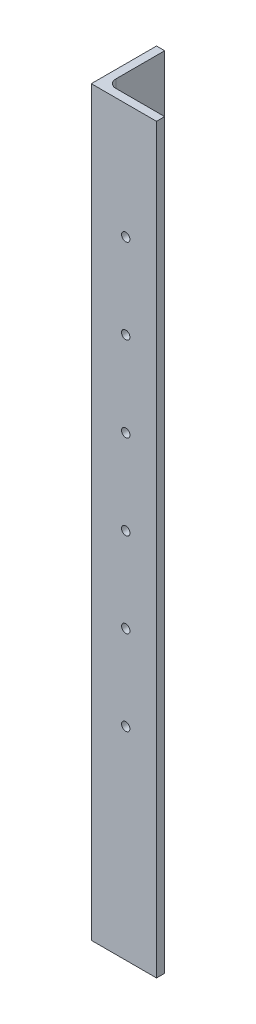
from build123d import *

# Parameters (mm, degrees)
BOSS_EXTRUDE1_DEPTH      = 577.85
FILLET1_R                = 6.35
F_0_257_DIAMETER_HOLE1_D = 6.5278
LPATTERN1_COUNT          = 6
LPATTERN1_PITCH          = 66.04
F_0_257_DIAMETER_HOLE2_D = 6.5278
LPATTERN2_COUNT          = 6
LPATTERN2_PITCH          = 66.04


with BuildPart() as part:
    # Sketch2 → Boss-Extrude1 (new body)
    with BuildSketch(Plane(origin=(0, 6.35, 0), x_dir=(1, 0, 0), z_dir=(0, 1, 0))):
        Polygon((-304.8, -406.4), (-304.8, -457.2), (-254, -457.2), (-254, -450.85), (-298.45, -450.85), (-298.45, -406.4), align=None)
    extrude(amount=BOSS_EXTRUDE1_DEPTH)

    # Fillet1
    fillet1_edges = [part.edges().sort_by_distance(p)[0] for p in [
        (-298.45, 295.275, 450.85),
    ]]
    fillet(fillet1_edges, radius=FILLET1_R)

    # F (0.257) Diameter Hole1 (through all)
    with Locations(Plane.XY.offset(457.2)):
        with Locations((-535.515028223, 347.01452534), (-277.982504407, 164.015269696)):
            f_0_257_diameter_hole1 = Hole(F_0_257_DIAMETER_HOLE1_D / 2)

    # LPattern1: F (0.257) Diameter Hole1 ×6
    with Locations(*[(0, i * LPATTERN1_PITCH, 0) for i in range(1, LPATTERN1_COUNT)]):
        add(f_0_257_diameter_hole1, mode=Mode.SUBTRACT)

    # F (0.257) Diameter Hole2 (through all)
    with Locations(Plane.ZY.offset(304.8)):
        with Locations((431.8, 164.015269696)):
            f_0_257_diameter_hole2 = Hole(F_0_257_DIAMETER_HOLE2_D / 2)

    # LPattern2: F (0.257) Diameter Hole2 ×6
    with Locations(*[(0, i * LPATTERN2_PITCH, 0) for i in range(1, LPATTERN2_COUNT)]):
        add(f_0_257_diameter_hole2, mode=Mode.SUBTRACT)


solid = part.part
